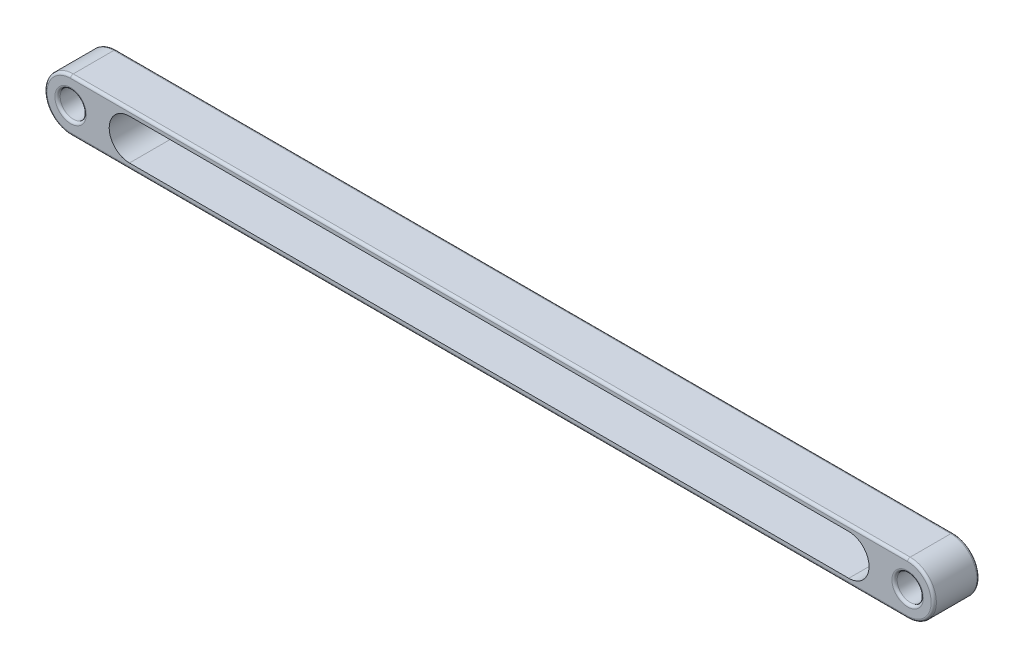
from build123d import *

# Parameters (mm, degrees)
BOSS_EXTRUDE2_DEPTH = 17.5
SKETCH5_R           = 10
CUT_EXTRUDE1_DEPTH  = 36
CUT_EXTRUDE2_DEPTH  = 40
FILLET1_R           = 2


with BuildPart() as part:
    # Sketch4 → Boss-Extrude2 (new body, symmetric)
    with BuildSketch(Plane.XY):
        with BuildLine():
            Line((-320, 20), (320, 20))
            ThreePointArc((320, 20), (340, 0), (320, -20))
            Line((320, -20), (-320, -20))
            ThreePointArc((-320, -20), (-340, 0), (-320, 20))
        make_face()
    extrude(amount=BOSS_EXTRUDE2_DEPTH, both=True)

    # Sketch5 → Cut-Extrude1 (cut, through all)
    with BuildSketch(Plane.XY.offset(17.5)):
        with Locations((320, 0)):
            Circle(SKETCH5_R)
        with Locations((-320, 0)):
            Circle(SKETCH5_R)
    extrude(amount=-CUT_EXTRUDE1_DEPTH, mode=Mode.SUBTRACT)

    # Sketch6 → Cut-Extrude2 (cut)
    with BuildSketch(Plane(origin=(0, 0, -17.5), x_dir=(-1, 0, 0), z_dir=(0, 0, -1))):
        with BuildLine():
            Line((-275, 15.5), (275, 15.5))
            ThreePointArc((275, 15.5), (290.5, 0), (275, -15.5))
            Line((275, -15.5), (-275, -15.5))
            ThreePointArc((-275, -15.5), (-290.5, 0), (-275, 15.5))
        make_face()
    extrude(amount=-CUT_EXTRUDE2_DEPTH, mode=Mode.SUBTRACT)

    # Fillet1
    fillet1_edges = [part.edges().sort_by_distance(p)[0] for p in [
        (340, 0, 17.5),
        (310, 0, -17.5),
        (310, 0, 17.5),
        (0, 20, 17.5),
        (-330, 0, -17.5),
        (-330, 0, 17.5),
        (-340, 0, 17.5),
        (0, 20, -17.5),
        (340, 0, -17.5),
        (0, -20, -17.5),
        (-340, 0, -17.5),
        (0, -20, 17.5),
    ]]
    fillet(fillet1_edges, radius=FILLET1_R)


solid = part.part
